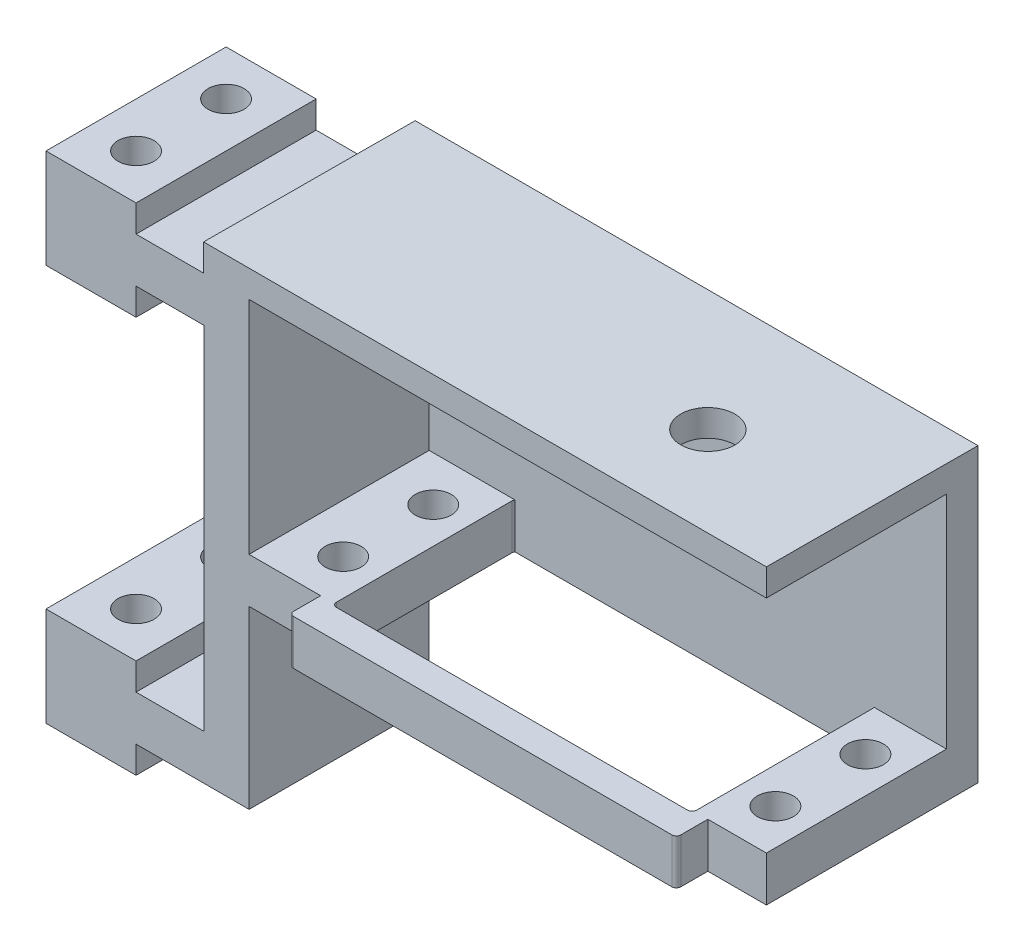
from build123d import *

# Parameters (mm, degrees)
BOSS_EXTRUDE1_DEPTH = 20
SKETCH3_W           = 15
SKETCH3_H           = 5
CUT_EXTRUDE2_DEPTH  = 8
SKETCH4_R           = 2
CUT_EXTRUDE3_DEPTH  = 110
SKETCH2_R           = 2
CUT_EXTRUDE4_DEPTH  = 110
SKETCH5_W           = 43
SKETCH5_H           = 27
BOSS_EXTRUDE2_DEPTH = 5
SKETCH6_W           = 40
SKETCH6_H           = 20.5
CUT_EXTRUDE5_DEPTH  = 5
FILLET1_R           = 0.5
BOSS_EXTRUDE3_DEPTH = 62.5
SKETCH8_R           = 3
CUT_EXTRUDE6_DEPTH  = 62.5


with BuildPart() as part:
    # Sketch1 → Boss-Extrude1 (new body)
    with BuildSketch(Plane.XY):
        Polygon((0, 0), (12.551397955, 0), (12.551397955, 19.52439682), (70, 19.52439682), (70, 24.52439682), (12.551397955, 24.52439682), (12.551397955, 49.048793639), (0, 49.048793639), (0, 52.048793639), (-10, 52.048793639), (-10, 41.048793639), (0, 41.048793639), (0, 44.048793639), (7.551397955, 44.048793639), (7.551397955, 24.52439682), (7.551397955, 5), (0, 5), (0, 8), (-10, 8), (-10, -3), (0, -3), align=None)
    extrude(amount=BOSS_EXTRUDE1_DEPTH)

    # Sketch3 → Cut-Extrude2 (cut)
    with BuildSketch(Plane.ZY.offset(10)):
        with Locations((10, 2.5)):
            Rectangle(SKETCH3_W, SKETCH3_H)
    cut_extrude2 = extrude(amount=-CUT_EXTRUDE2_DEPTH, mode=Mode.SUBTRACT)

    # Mirror1: Cut-Extrude2 across plane
    add(cut_extrude2.mirror(Plane(origin=(12.551397955, 24.52439682, 20), x_dir=(0, 0, 1), z_dir=(0, -1, 0))), mode=Mode.SUBTRACT)

    # Sketch4 → Cut-Extrude3 (cut)
    with BuildSketch(Plane(origin=(0, 52.048793639, 0), x_dir=(1, 0, 0), z_dir=(0, 1, 0))):
        with Locations((-5, -5)):
            Circle(SKETCH4_R)
        with Locations((-5, -15)):
            Circle(SKETCH4_R)
    extrude(amount=-CUT_EXTRUDE3_DEPTH, mode=Mode.SUBTRACT)

    # Sketch2 → Cut-Extrude4 (cut)
    with BuildSketch(Plane.XZ.offset(-19.52439682)):
        with Locations((66, 15)):
            Circle(SKETCH2_R)
        with Locations((18, 15)):
            Circle(SKETCH2_R)
        with Locations((18, 5)):
            Circle(SKETCH2_R)
        with Locations((66, 5)):
            Circle(SKETCH2_R)
    extrude(amount=-CUT_EXTRUDE4_DEPTH, mode=Mode.SUBTRACT)

    # Sketch5 → Boss-Extrude2 (add)
    with BuildSketch(Plane.XZ.offset(-19.52439682)):
        with Locations((42, 10)):
            Rectangle(SKETCH5_W, SKETCH5_H)
    extrude(amount=-BOSS_EXTRUDE2_DEPTH)

    # Sketch6 → Cut-Extrude5 (cut)
    with BuildSketch(Plane.XZ.offset(-19.52439682)):
        with Locations((42, 10)):
            Rectangle(SKETCH6_W, SKETCH6_H)
    extrude(amount=-CUT_EXTRUDE5_DEPTH, mode=Mode.SUBTRACT)

    # Fillet1
    fillet1_edges = [part.edges().sort_by_distance(p)[0] for p in [
        (63.5, 22.02439682, 23.5),
        (63.5, 22.02439682, -3.5),
        (20.5, 22.02439682, -3.5),
        (20.5, 22.02439682, 23.5),
        (62, 22.02439682, 20.25),
        (62, 22.02439682, -0.25),
        (22, 22.02439682, -0.25),
        (22, 22.02439682, 20.25),
    ]]
    fillet(fillet1_edges, radius=FILLET1_R)

    # Sketch7 → Boss-Extrude3 (add)
    with BuildSketch(Plane(origin=(70, 0, 0), x_dir=(0, 0, -1), z_dir=(1, 0, 0))):
        Polygon((0, 19.52439682), (3.5, 19.52439682), (3.5, 51.958822175), (-20, 52.048793639), (-20, 49.048793639), (0, 49.048793639), align=None)
    extrude(amount=-BOSS_EXTRUDE3_DEPTH)

    # Sketch8 → Cut-Extrude6 (cut)
    with BuildSketch(Plane(origin=(0, 51.971460384, -0.198976528), x_dir=(1, 0, 0), z_dir=(0, 0.999992671, -0.003828545))):
        with Locations((53.5, -10.198952335)):
            Circle(SKETCH8_R)
    extrude(amount=-CUT_EXTRUDE6_DEPTH, mode=Mode.SUBTRACT)


solid = part.part
